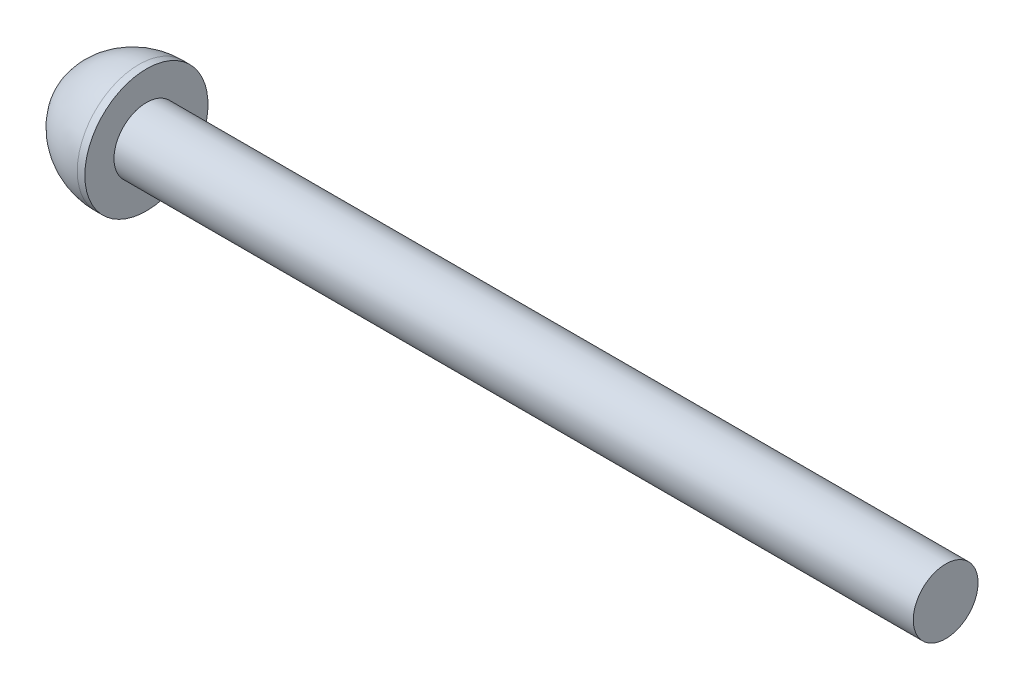
from build123d import *

# Parameters (mm, degrees)
CUT_EXTRUDE1_DEPTH = 1
SCALE1_SCALE       = 1.7


with BuildPart() as part:
    # Sketch1 → Revolve1 (revolve)
    with BuildSketch(Plane.XY):
        with BuildLine():
            Line((0, 0), (0, 1.43))
            ThreePointArc((0, 1.43), (1.238500708, 2.474899998), (2.814888985, 2.85))
            Line((2.814888985, 2.85), (3.164888985, 2.85))
            Line((3.164888985, 2.85), (3.164888985, 1.5))
            Line((3.164888985, 1.5), (40.164888985, 1.5))
            Line((40.164888985, 1.5), (40.164888985, 0))
            Line((40.164888985, 0), (0, 0))
        make_face()
    revolve(axis=Axis((0, 0, 0), (1, 0, 0)))

    # Sketch2 → Cut-Extrude1 (cut)
    with BuildSketch(Plane.ZY):
        Polygon((1, 0), (0.5, 0.866025404), (-0.5, 0.866025404), (-1, 0), (-0.5, -0.866025404), (0.5, -0.866025404), align=None)
    extrude(amount=-CUT_EXTRUDE1_DEPTH, mode=Mode.SUBTRACT)


with BuildPart() as part_1:
    # Scale1: scaled about (17.990832775, 0, 0)
    add(part.part.scale(SCALE1_SCALE).moved(Location((-12.593582942, 0, 0))))


solid = part_1.part
